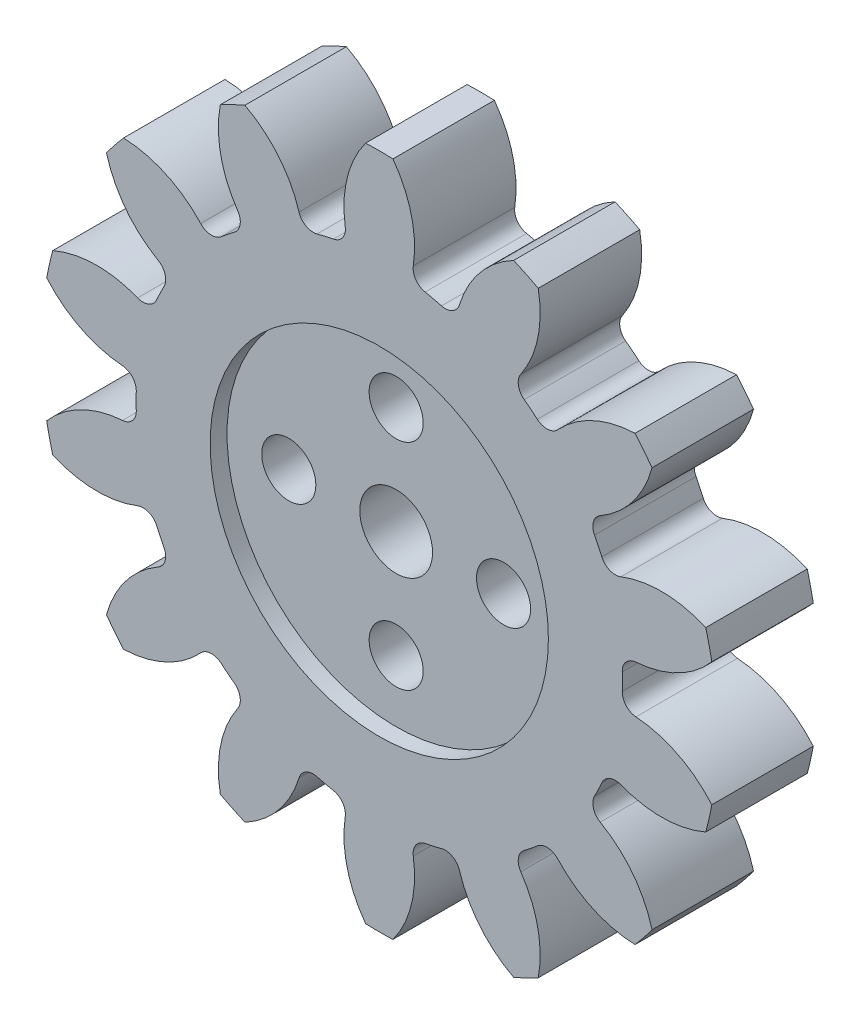
from build123d import *

# Parameters (mm, degrees)
BOSS_EXTRU_1_DEPTH                 = 6
CONG_1_R                           = 0.875
R_P_TITION_CIRCULAIRE4_COUNT       = 14
CONG_1_OF_R_P_TITION_CIRCULAIRE4_R = 0.875
ESQUISSE6_R                        = 10
ENL_V_MAT_EXTRU_1_DEPTH            = 1
ESQUISSE7_R                        = 2.15
ENL_V_MAT_EXTRU_2_DEPTH            = 6.0000001
ESQUISSE8_R                        = 1.6
ENL_V_MAT_EXTRU_3_DEPTH            = 6.0000001
ENL_V_MAT_EXTRU_4_DEPTH            = 2.5


with BuildPart() as part:
    # Esquisse3 → Boss.-Extru.1 (new body)
    with BuildSketch(Plane.XY):
        with BuildLine():
            Line((-4.577445339, 13.454236279), (-1.378706913, -0.560352459))
            Line((-1.378706913, -0.560352459), (1.820031512, 13.454236279))
            ThreePointArc((1.820031512, 13.454236279), (1.134989636, 13.593161404), (0.444004358, 13.69862186))
            ThreePointArc((0.444004358, 13.69862186), (0.608952116, 16.680304966), (-0.571450192, 19.423349315))
            ThreePointArc((-0.571450192, 19.423349315), (-1.378706913, 19.439647541), (-2.185963634, 19.423349315))
            ThreePointArc((-2.185963634, 19.423349315), (-3.366365942, 16.680304966), (-3.201418184, 13.69862186))
            ThreePointArc((-3.201418184, 13.69862186), (-3.892403463, 13.593161404), (-4.577445339, 13.454236279))
        make_face()
    boss_extru_1 = extrude(amount=BOSS_EXTRU_1_DEPTH)

    # Cong_1
    cong_1_edges = [part.edges().sort_by_distance(p)[0] for p in [
        (-3.201418184, 13.69862186, 3),
        (0.444004358, 13.69862186, 3),
    ]]
    fillet(cong_1_edges, radius=CONG_1_R)

    # R_p_tition circulaire4: Boss.-Extru.1 ×14 about axis
    r_p_tition_circulaire4_axis = Axis((-1.378706913, -0.560352459, 0), (0, 0, 1))
    for i in range(1, R_P_TITION_CIRCULAIRE4_COUNT):
        add(boss_extru_1.rotate(r_p_tition_circulaire4_axis, i * 360 / R_P_TITION_CIRCULAIRE4_COUNT))

    # Cong_1 of R_p_tition circulaire4
    cong_1_of_r_p_tition_circulaire4_edges = [part.edges().sort_by_distance(p)[0] for p in [
        (-9.207650117, 11.495694709, 3),
        (-5.923237896, 13.077384272, 3),
        (-13.663263833, 6.904919559, 3),
        (-11.390380054, 9.755025669, 3),
        (-15.68577039, 0.83555573, 3),
        (-14.874587561, 4.389579918, 3),
        (-14.874587561, -5.510284835, 3),
        (-15.68577039, -1.956260647, 3),
        (-11.390380054, -10.875730587, 3),
        (-13.663263833, -8.025624476, 3),
        (-5.923237896, -14.19808919, 3),
        (-9.207650117, -12.616399626, 3),
        (0.444004358, -14.819326777, 3),
        (-3.201418184, -14.819326777, 3),
        (6.450236291, -12.616399626, 3),
        (3.16582407, -14.19808919, 3),
        (10.905850006, -8.025624476, 3),
        (8.632966228, -10.875730587, 3),
        (12.928356564, -1.956260647, 3),
        (12.117173735, -5.510284835, 3),
        (12.117173735, 4.389579918, 3),
        (12.928356564, 0.83555573, 3),
        (8.632966228, 9.755025669, 3),
        (10.905850006, 6.904919559, 3),
        (3.16582407, 13.077384272, 3),
        (6.450236291, 11.495694709, 3),
    ]]
    fillet(cong_1_of_r_p_tition_circulaire4_edges, radius=CONG_1_OF_R_P_TITION_CIRCULAIRE4_R)

    # Esquisse6 → Enl_v. mat.-Extru.1 (cut)
    with BuildSketch(Plane.XY.offset(6)):
        with Locations((-1.378706913, -0.560352459)):
            Circle(ESQUISSE6_R)
    extrude(amount=-ENL_V_MAT_EXTRU_1_DEPTH, mode=Mode.SUBTRACT)

    # Esquisse7 → Enl_v. mat.-Extru.2 (cut, through all)
    with BuildSketch(Plane.XY.offset(5)):
        with Locations((-1.378706913, -0.560352459)):
            Circle(ESQUISSE7_R)
    extrude(amount=-ENL_V_MAT_EXTRU_2_DEPTH, mode=Mode.SUBTRACT)

    # Esquisse8 → Enl_v. mat.-Extru.3 (cut, through all)
    with BuildSketch(Plane.XY.offset(5)):
        with Locations((-7.728706913, -0.560352459)):
            Circle(ESQUISSE8_R)
        with Locations(Location((4.971293087, -0.560352459, 0), (0, 0, 180))):  # turned: the seam where the file's is
            Circle(ESQUISSE8_R)
        with Locations((-1.378706913, 5.789647541)):
            Circle(ESQUISSE8_R)
        with Locations((-1.378706913, -6.910352459)):
            Circle(ESQUISSE8_R)
    extrude(amount=-ENL_V_MAT_EXTRU_3_DEPTH, mode=Mode.SUBTRACT)

    # Esquisse9 → Enl_v. mat.-Extru.4 (cut)
    with BuildSketch(Plane(origin=(0, 0, 0), x_dir=(-1, 0, 0), z_dir=(0, 0, -1))):
        Polygon((-1.940204174, -2.310352459), (-1.940204174, 1.189647541), (-4.971293087, 2.939647541), (-8.002382, 1.189647541), (-8.002382, -2.310352459), (-4.971293087, -4.060352459), align=None)
        Polygon((7.728706913, -4.060352459), (10.759795826, -2.310352459), (10.759795826, 1.189647541), (7.728706913, 2.939647541), (4.697618, 1.189647541), (4.697618, -2.310352459), align=None)
        Polygon((3.128706913, 2.758558628), (4.878706913, 5.789647541), (3.128706913, 8.820736455), (-0.371293087, 8.820736455), (-2.121293087, 5.789647541), (-0.371293087, 2.758558628), align=None)
        Polygon((3.128706913, -9.941441372), (4.878706913, -6.910352459), (3.128706913, -3.879263545), (-0.371293087, -3.879263545), (-2.121293087, -6.910352459), (-0.371293087, -9.941441372), align=None)
    extrude(amount=-ENL_V_MAT_EXTRU_4_DEPTH, mode=Mode.SUBTRACT)


solid = part.part
